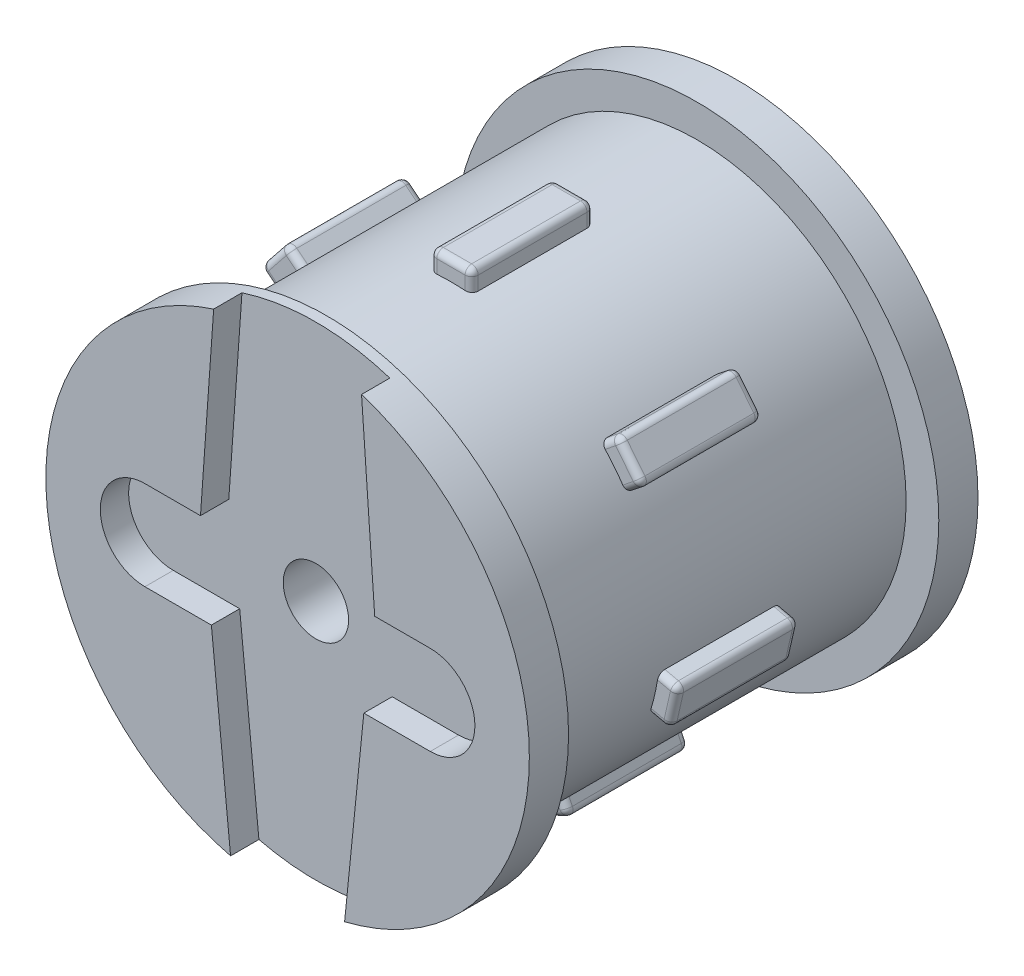
from build123d import *

# Parameters (mm, degrees)
SKIZZE1_R                            = 9.6
AUFSATZ_LINEAR_AUSTRAGEN1_DEPTH      = 10.3
AUFSATZ_LINEAR_AUSTRAGEN1_DEPTH_BACK = 10.3
SKIZZE2_R                            = 11.1
AUFSATZ_LINEAR_AUSTRAGEN2_DEPTH      = 1.8
SKIZZE3_R                            = 11.1
AUFSATZ_LINEAR_AUSTRAGEN3_DEPTH      = 1.8
SCHNITT_LINEAR_AUSTRAGEN1_DEPTH      = 1.3
SKIZZE11_W                           = 1.9
SKIZZE11_H                           = 1.78
AUFSATZ_LINEAR_AUSTRAGEN4_DEPTH      = 2.8
KREISMUSTER2_COUNT                   = 7
VERRUNDUNG1_R                        = 0.3
SKIZZE14_R                           = 1.5
SCHNITT_LINEAR_AUSTRAGEN2_DEPTH      = 3.6


with BuildPart() as part:
    # Skizze1 → Aufsatz-Linear austragen1 (new body, two sides)
    with BuildSketch(Plane.XY) as aufsatz_linear_austragen1_sk:
        Circle(SKIZZE1_R)
    extrude(amount=AUFSATZ_LINEAR_AUSTRAGEN1_DEPTH)
    extrude(aufsatz_linear_austragen1_sk.sketch, amount=-AUFSATZ_LINEAR_AUSTRAGEN1_DEPTH_BACK)

    # Skizze2 → Aufsatz-Linear austragen2 (add)
    with BuildSketch(Plane.XY.offset(10.3)):
        Circle(SKIZZE2_R)
    extrude(amount=-AUFSATZ_LINEAR_AUSTRAGEN2_DEPTH)

    # Skizze3 → Aufsatz-Linear austragen3 (add)
    with BuildSketch(Plane(origin=(0, 0, -10.3), x_dir=(-1, 0, 0), z_dir=(0, 0, -1))):
        Circle(SKIZZE3_R)
    extrude(amount=-AUFSATZ_LINEAR_AUSTRAGEN3_DEPTH)

    # Skizze12 → Schnitt-Linear austragen1 (cut)
    with BuildSketch(Plane.XY.offset(10.3)):
        with BuildLine():
            Line((1.989875391, -17.000987381), (3.5, -2.05))
            Line((3.5, -2.05), (6.55, -2.05))
            ThreePointArc((6.55, -2.05), (8.6, 0), (6.55, 2.05))
            Line((6.55, 2.05), (4, 2.05))
            Line((4, 2.05), (2.743088397, 19.744848776))
            ThreePointArc((2.743088397, 19.744848776), (0, 16.8), (-2.743088397, 19.744848776))
            Line((-2.743088397, 19.744848776), (-4, 2.05))
            Line((-4, 2.05), (-6.55, 2.05))
            ThreePointArc((-6.55, 2.05), (-8.6, 0), (-6.55, -2.05))
            Line((-6.55, -2.05), (-3.5, -2.05))
            Line((-3.5, -2.05), (-1.989875391, -17.000987381))
            ThreePointArc((-1.989875391, -17.000987381), (0, -14.8), (1.989875391, -17.000987381))
        make_face()
    extrude(amount=-SCHNITT_LINEAR_AUSTRAGEN1_DEPTH, mode=Mode.SUBTRACT)

    # Skizze8 → Schnitt-Rotation1 (revolve, cut)
    with BuildSketch(Plane(origin=(0, 0, 0), x_dir=(0, 0, -1), z_dir=(1, 0, 0))):
        Polygon((10.3, 0), (10.3, 8), (8.5, 8), (-6.7, 6), (-6.7, 0), align=None)
    revolve(axis=Axis((0, 0, -10.3), (0, 0, 1)), mode=Mode.SUBTRACT)

    # Skizze11 → Aufsatz-Linear austragen4 (add, symmetric)
    with BuildSketch(Plane(origin=(0, 0, 0), x_dir=(-1, 0, 0), z_dir=(0, 0, -1))):
        with Locations((0, 9.6)):
            Rectangle(SKIZZE11_W, SKIZZE11_H)
    aufsatz_linear_austragen4 = extrude(amount=AUFSATZ_LINEAR_AUSTRAGEN4_DEPTH, both=True)

    # Kreismuster2: Aufsatz-Linear austragen4 ×7 about axis
    kreismuster2_axis = Axis((0, 0, 0), (0, 0, 1))
    for i in range(1, KREISMUSTER2_COUNT):
        add(aufsatz_linear_austragen4.rotate(kreismuster2_axis, i * 360 / KREISMUSTER2_COUNT))

    # Verrundung1
    verrundung1_edges = [part.edges().sort_by_distance(p)[0] for p in [
        (-9.558786273, -3.15616161, 2.8),
        (-10.015598912, -3.260426114, 0),
        (-9.981576048, -1.303798577, 2.8),
        (-10.438388686, -1.408063081, 0),
        (-10.226993799, -2.334244597, 2.8),
        (-9.558786273, -3.15616161, -2.8),
        (-10.226993799, -2.334244597, -2.8),
        (-9.981576048, -1.303798577, -2.8),
        (-3.492219249, -9.44119462, 2.8),
        (-3.695519999, -9.863352976, 0),
        (-5.204060098, -8.616815515, 2.8),
        (-5.407360848, -9.038973872, 0),
        (-4.551440423, -9.451163424, 2.8),
        (-3.492219249, -9.44119462, -2.8),
        (-4.551440423, -9.451163424, -2.8),
        (-5.204060098, -8.616815515, -2.8),
        (5.204060098, -8.616815515, 2.8),
        (5.407360848, -9.038973872, 0),
        (3.492219249, -9.44119462, 2.8),
        (3.695519999, -9.863352976, 0),
        (4.551440423, -9.451163424, 2.8),
        (5.204060098, -8.616815515, -2.8),
        (4.551440423, -9.451163424, -2.8),
        (3.492219249, -9.44119462, -2.8),
        (9.981576048, -1.303798577, 2.8),
        (10.438388686, -1.408063081, 0),
        (9.558786273, -3.15616161, 2.8),
        (10.015598912, -3.260426114, 0),
        (10.226993799, -2.334244597, 2.8),
        (9.981576048, -1.303798577, -2.8),
        (10.226993799, -2.334244597, -2.8),
        (9.558786273, -3.15616161, -2.8),
        (7.242761647, 6.991005282, 2.8),
        (7.609096939, 7.28314793, 0),
        (8.42739227, 5.505525466, 2.8),
        (8.793727563, 5.797668113, 0),
        (8.201412251, 6.540408021, 2.8),
        (7.242761647, 6.991005282, -2.8),
        (8.201412251, 6.540408021, -2.8),
        (8.42739227, 5.505525466, -2.8),
        (-0.95, 10.021439574, 2.8),
        (-0.95, 10.49, 0),
        (0.95, 10.021439574, 2.8),
        (0.95, 10.49, 0),
        (0, 10.49, 2.8),
        (-0.95, 10.021439574, -2.8),
        (0, 10.49, -2.8),
        (0.95, 10.021439574, -2.8),
        (-8.42739227, 5.505525466, 2.8),
        (-8.793727563, 5.797668113, 0),
        (-7.242761647, 6.991005282, 2.8),
        (-7.609096939, 7.28314793, 0),
        (-8.201412251, 6.540408021, 2.8),
        (-8.42739227, 5.505525466, -2.8),
        (-8.201412251, 6.540408021, -2.8),
        (-7.242761647, 6.991005282, -2.8),
    ]]
    fillet(verrundung1_edges, radius=VERRUNDUNG1_R)

    # Skizze14 → Schnitt-Linear austragen2 (cut)
    with BuildSketch(Plane.XY.offset(10.3)):
        Circle(SKIZZE14_R)
    extrude(amount=-SCHNITT_LINEAR_AUSTRAGEN2_DEPTH, mode=Mode.SUBTRACT)


solid = part.part
